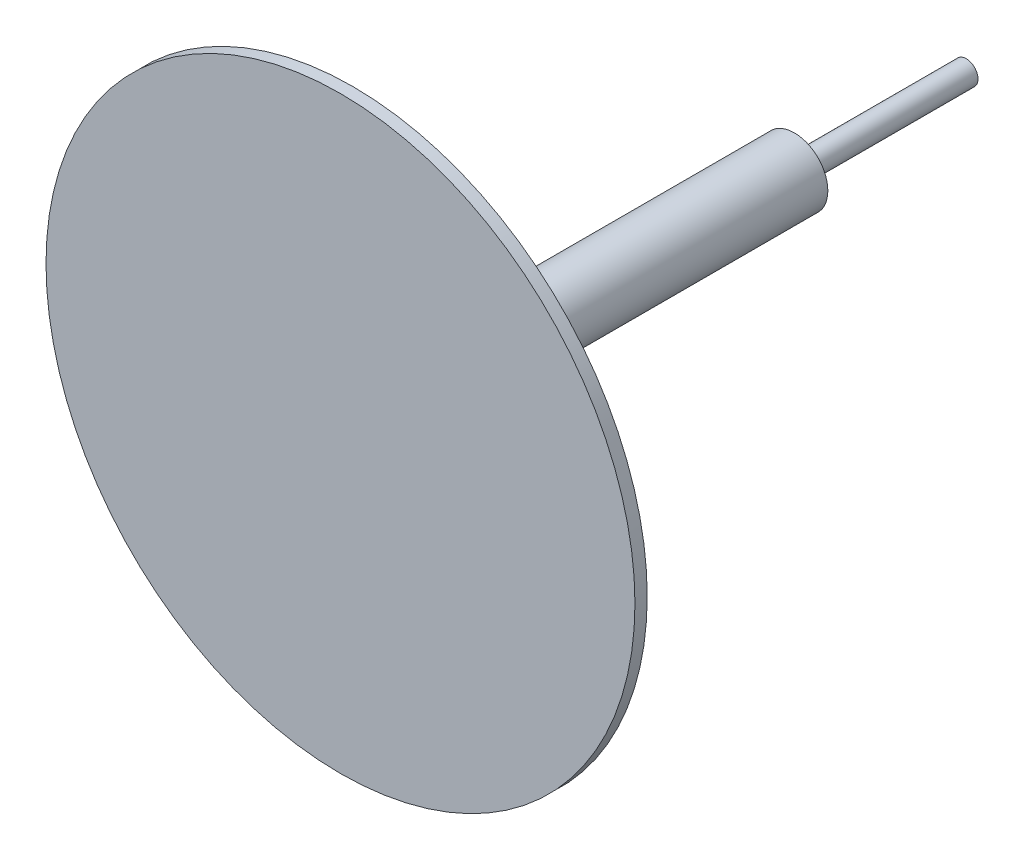
from build123d import *

# Parameters (mm, degrees)
SKETCH1_R           = 15.24
BOSS_EXTRUDE1_DEPTH = 0.635
SKETCH2_R           = 1.7272
BOSS_EXTRUDE2_DEPTH = 22.86
SKETCH3_R           = 0.6096
BOSS_EXTRUDE3_DEPTH = 8.89


with BuildPart() as part:
    # Sketch1 → Boss-Extrude1 (new body)
    with BuildSketch(Plane.XY):
        Circle(SKETCH1_R)
    extrude(amount=BOSS_EXTRUDE1_DEPTH)

    # Sketch2 → Boss-Extrude2 (add)
    with BuildSketch(Plane(origin=(0, 0, 0), x_dir=(-1, 0, 0), z_dir=(0, 0, -1))):
        Circle(SKETCH2_R)
    extrude(amount=BOSS_EXTRUDE2_DEPTH)

    # Sketch3 → Boss-Extrude3 (add)
    with BuildSketch(Plane(origin=(0, 0, -22.86), x_dir=(-1, 0, 0), z_dir=(0, 0, -1))):
        Circle(SKETCH3_R)
    extrude(amount=BOSS_EXTRUDE3_DEPTH)


solid = part.part
